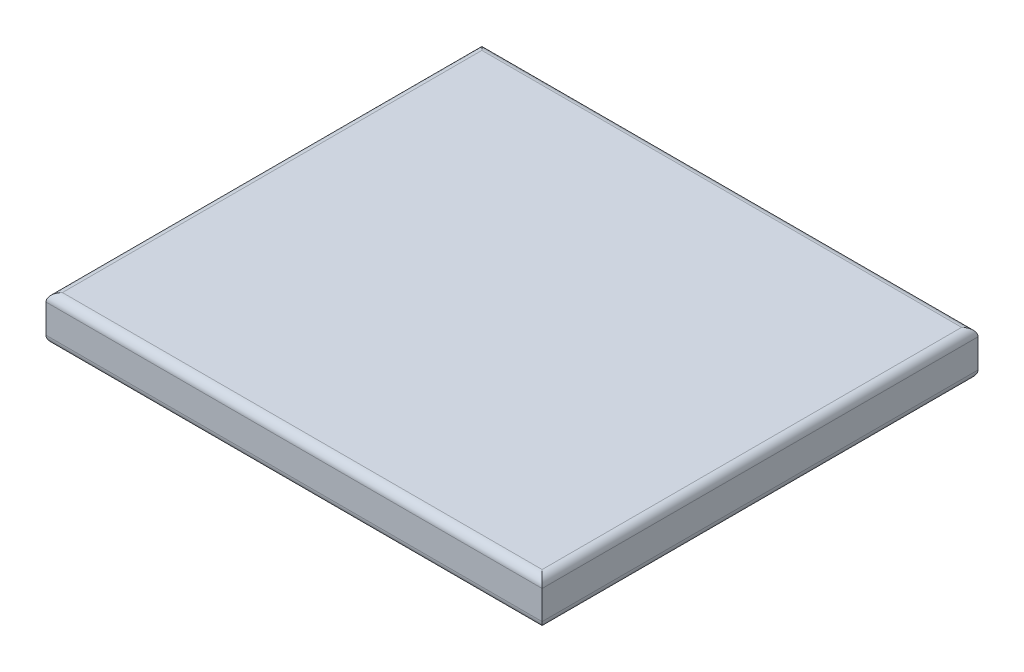
from build123d import *

# Parameters (mm, degrees)
SKETCH1_W           = 60.5
SKETCH1_H           = 53.15
BOSS_EXTRUDE1_DEPTH = 5.5
FILLET1_R           = 1


with BuildPart() as part:
    # Sketch1 → Boss-Extrude1 (new body)
    with BuildSketch(Plane(origin=(0, 0, 0), x_dir=(1, 0, 0), z_dir=(0, 1, 0))):
        with Locations((30.25, 26.575)):
            Rectangle(SKETCH1_W, SKETCH1_H)
    extrude(amount=BOSS_EXTRUDE1_DEPTH)

    # Fillet1
    fillet1_edges = [part.edges().sort_by_distance(p)[0] for p in [
        (60.5, 5.5, -26.575),
        (30.25, 5.5, -53.15),
        (0, 5.5, -26.575),
        (30.25, 0, -53.15),
        (60.5, 0, -26.575),
        (30.25, 0, 0),
        (0, 0, -26.575),
        (30.25, 5.5, 0),
    ]]
    fillet(fillet1_edges, radius=FILLET1_R)


solid = part.part
